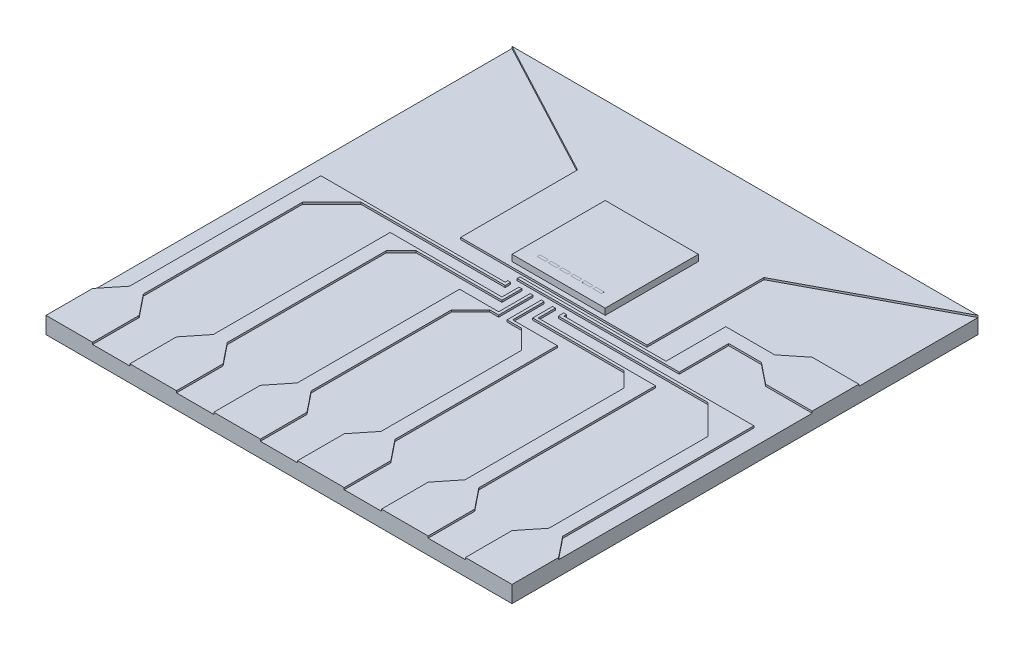
from build123d import *

# Parameters (mm, degrees)
SKETCH3_W           = 50
SKETCH3_H           = 50
BOSS_EXTRUDE1_DEPTH = 1.5875
BOSS_EXTRUDE2_DEPTH = 0.204346
SKETCH4_W           = 10
SKETCH4_H           = 10
BOSS_EXTRUDE3_DEPTH = 0.675
SKETCH5_W           = 0.9
SKETCH5_H           = 0.3
BOSS_EXTRUDE4_DEPTH = 0.001


with BuildPart() as part:
    # Sketch3 → Boss-Extrude1 (new body)
    with BuildSketch(Plane(origin=(0, 0, 0), x_dir=(1, 0, 0), z_dir=(0, 1, 0))):
        with Locations((22.488763021, 23.818655395)):
            Rectangle(SKETCH3_W, SKETCH3_H)
    extrude(amount=-BOSS_EXTRUDE1_DEPTH)

    # Sketch2 → Boss-Extrude2 (add)
    with BuildSketch(Plane(origin=(0, 0, 0), x_dir=(1, 0, 0), z_dir=(0, 1, 0))):
        Polygon((32.488763021, 28.302249005), (32.488763021, 40.851579566), (47.488763021, 48.818655395), (-2.511236979, 48.818655395), (12.488763021, 40.851579566), (12.488763021, 28.302249005), align=None)
        Polygon((47.488763021, 31.033343899), (47.488763021, 36.033343899), (42.488763021, 36.033343899), (40.243873607, 34.239185764), (35.010861347, 34.239185764), (35.010861347, 27.818655395), (19.338763021, 27.818655395), (19.338763021, 27.518655395), (36.72925203, 27.518655395), (36.72925203, 32.827502034), (40.243873607, 32.827502034), (42.488763021, 31.033343899), align=None)
        Polygon((47.488763021, -1.181344605), (47.488763021, 3.818655395), (45.72925203, 6.01706342), (45.72925203, 26.536834752), (25.338763021, 26.536834752), (25.338763021, 26.818655395), (25.038763021, 26.818655395), (25.038763021, 26.236834752), (41.093092119, 26.236834752), (44.248274012, 23.081652859), (44.248274012, 6.01706342), (42.488763021, 3.818655395), (42.488763021, -1.181344605), align=None)
        Polygon((33.488763021, -1.181344605), (38.488763021, -1.181344605), (38.488763021, 3.818655395), (36.72925203, 6.01706342), (36.72925203, 24.975395702), (24.138763021, 24.975395702), (24.138763021, 26.818655395), (23.838763021, 26.818655395), (23.838763021, 24.686834752), (33.643092119, 24.686834752), (35.248274012, 23.081652859), (35.248274012, 6.01706342), (33.488763021, 3.818655395), align=None)
        Polygon((24.488763021, 3.818655395), (24.488763021, -1.181344605), (29.488763021, -1.181344605), (29.488763021, 3.818655395), (27.72925203, 6.01706342), (27.72925203, 23.436834752), (22.938763021, 23.436834752), (22.938763021, 26.818655395), (22.638763021, 26.818655395), (22.638763021, 23.136834752), (24.213594494, 23.136834752), (26.248274012, 21.102155233), (26.248274012, 6.01706342), align=None)
        Polygon((15.488763021, 3.818655395), (15.488763021, -1.181344605), (20.488763021, -1.181344605), (20.488763021, 3.818655395), (18.72925203, 6.01706342), (18.731288885, 21.102155233), (20.765968404, 23.136834752), (21.738763021, 23.136834752), (21.738763021, 26.818655395), (21.438763021, 26.818655395), (21.438763021, 23.436834752), (17.248274012, 23.436834752), (17.248274012, 6.01706342), align=None)
        Polygon((6.488763021, 3.818655395), (6.488763021, -1.181344605), (11.488763021, -1.181344605), (11.488763021, 3.818655395), (9.732070762, 6.01706342), (9.732070762, 23.081652859), (11.325813604, 24.686834752), (20.538763021, 24.686834752), (20.538763021, 26.818655395), (20.238763021, 26.818655395), (20.238763021, 24.986834752), (8.24545528, 24.986834752), (8.24545528, 6.01706342), align=None)
        Polygon((-0.735853149, 6.01706342), (-2.511236979, 3.818655395), (-2.511236979, -1.181344605), (2.488763021, -1.181344605), (2.488763021, 3.818655395), (0.729267736, 6.01706342), (0.729267736, 23.081652859), (3.884449629, 26.236834752), (19.338763021, 26.236834752), (19.338763021, 26.818655395), (19.038763021, 26.818655395), (19.038763021, 26.536834752), (-0.735853149, 26.536834752), align=None)
    extrude(amount=BOSS_EXTRUDE2_DEPTH)

    # Sketch4 → Boss-Extrude3 (add)
    with BuildSketch(Plane(origin=(0, 0.204346, 0), x_dir=(1, 0, 0), z_dir=(0, 1, 0))):
        with Locations((22.488763021, 33.818655395)):
            Rectangle(SKETCH4_W, SKETCH4_H)
    extrude(amount=BOSS_EXTRUDE3_DEPTH)

    # Sketch5 → Boss-Extrude4 (add)
    with BuildSketch(Plane(origin=(0, 0.879346, 0), x_dir=(1, 0, 0), z_dir=(0, 1, 0))):
        with Locations((19.488763021, 30.118655395)):
            Rectangle(SKETCH5_W, SKETCH5_H)
        with Locations((20.688763021, 30.118655395)):
            Rectangle(SKETCH5_W, SKETCH5_H)
        with Locations((21.888763021, 30.118655395)):
            Rectangle(SKETCH5_W, SKETCH5_H)
        with Locations((23.088763021, 30.118655395)):
            Rectangle(SKETCH5_W, SKETCH5_H)
        with Locations((24.288763021, 30.118655395)):
            Rectangle(SKETCH5_W, SKETCH5_H)
        with Locations((25.488763021, 30.118655395)):
            Rectangle(SKETCH5_W, SKETCH5_H)
    extrude(amount=BOSS_EXTRUDE4_DEPTH)


solid = part.part
